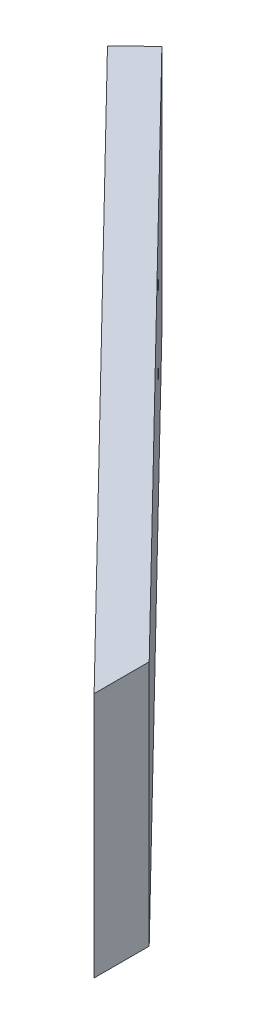
from build123d import *

# Parameters (mm, degrees)
BOSS_EXTRUDE1_DEPTH = 32
FILLET1_R           = 10
SKETCH4_W           = 170.11041037
SKETCH4_H           = 258.008077424
CUT_EXTRUDE2_DEPTH  = 33
SKETCH5_R           = 1.1
CUT_EXTRUDE3_DEPTH  = 57.514129524
SKETCH6_R           = 1.1
CUT_EXTRUDE4_DEPTH  = 57.514129524


with BuildPart() as part:
    # Sketch1 → Boss-Extrude1 (new body)
    with BuildSketch(Plane(origin=(0, 0, 0), x_dir=(1, 0, 0), z_dir=(0, 1, 0))):
        Polygon((0, 0), (0, 30), (83, 115), (83, 107.843231513), (5, 27.963713441), (5, -27.963713441), (83, -107.843231513), (83, -115), (0, -30), align=None)
    extrude(amount=BOSS_EXTRUDE1_DEPTH)

    # Fillet1
    fillet1_edges = [part.edges().sort_by_distance(p)[0] for p in [
        (0, 16, 30),
        (0, 16, -30),
    ]]
    fillet(fillet1_edges, radius=FILLET1_R)

    # Sketch4 → Cut-Extrude2 (cut, through all)
    with BuildSketch(Plane(origin=(0, 32, 0), x_dir=(1, 0, 0), z_dir=(0, 1, 0))):
        with Locations((35.635219957, -4.046970822)):
            Rectangle(SKETCH4_W, SKETCH4_H)
        Polygon((14.577370106, -37.771863549), (86.577370106, -111.506803308), (83, -115), (11, -41.265060241), align=None, mode=Mode.SUBTRACT)
    extrude(amount=-CUT_EXTRUDE2_DEPTH, mode=Mode.SUBTRACT)

    # Sketch5 → Cut-Extrude3 (cut, through all)
    with BuildSketch(Plane(origin=(-11.418378796, 0, 11.14971106), x_dir=(-0.698639338, 0, -0.715474021), z_dir=(0.715474021, 0, -0.698639338))):
        with Locations((-40.209111306, 26)):
            Circle(SKETCH5_R)
        with Locations((-40.209111306, 6)):
            Circle(SKETCH5_R)
    extrude(amount=-CUT_EXTRUDE3_DEPTH, mode=Mode.SUBTRACT)

    # Sketch6 → Cut-Extrude4 (cut, through all)
    with BuildSketch(Plane(origin=(-11.418378796, 0, 11.14971106), x_dir=(-0.698639338, 0, -0.715474021), z_dir=(0.715474021, 0, -0.698639338))):
        with Locations((-66.177603446, 25)):
            Circle(SKETCH6_R)
        with Locations((-66.177603446, 15)):
            Circle(SKETCH6_R)
        with Locations((-106.177603446, 15)):
            Circle(SKETCH6_R)
        with Locations((-106.177603446, 25)):
            Circle(SKETCH6_R)
        with Locations((-86.177603446, 17)):
            Circle(SKETCH6_R)
        with Locations((-86.177603446, 7)):
            Circle(SKETCH6_R)
    extrude(amount=-CUT_EXTRUDE4_DEPTH, mode=Mode.SUBTRACT)


solid = part.part
